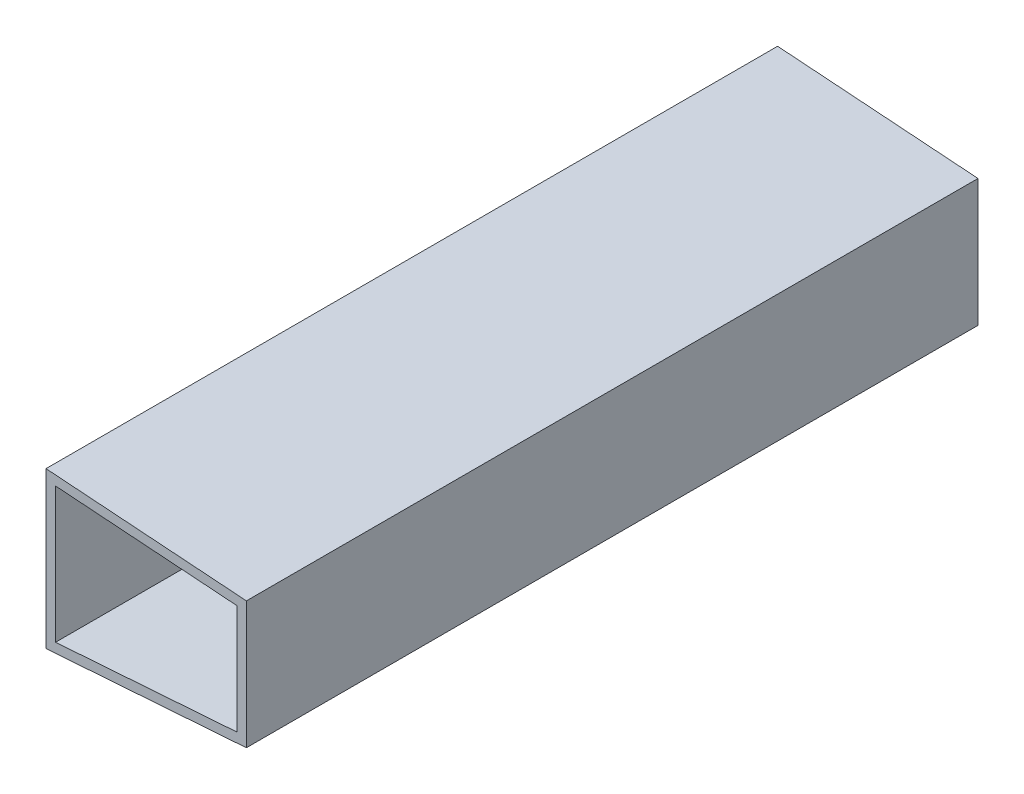
from build123d import *

# Parameters (mm, degrees)
EXTRUDE_THIN1_DEPTH = 230


with BuildPart() as part:
    # Sketch1 → Extrude-Thin1 (new body)
    with BuildSketch(Plane.XY):
        Polygon((0, -24.5), (0, 24.5), (63, 20), (63, -20), align=None)
        Polygon((3, -21.278070961), (3, 21.278070961), (60, 17.20664239), (60, -17.20664239), align=None, mode=Mode.SUBTRACT)
    extrude(amount=EXTRUDE_THIN1_DEPTH)


solid = part.part
